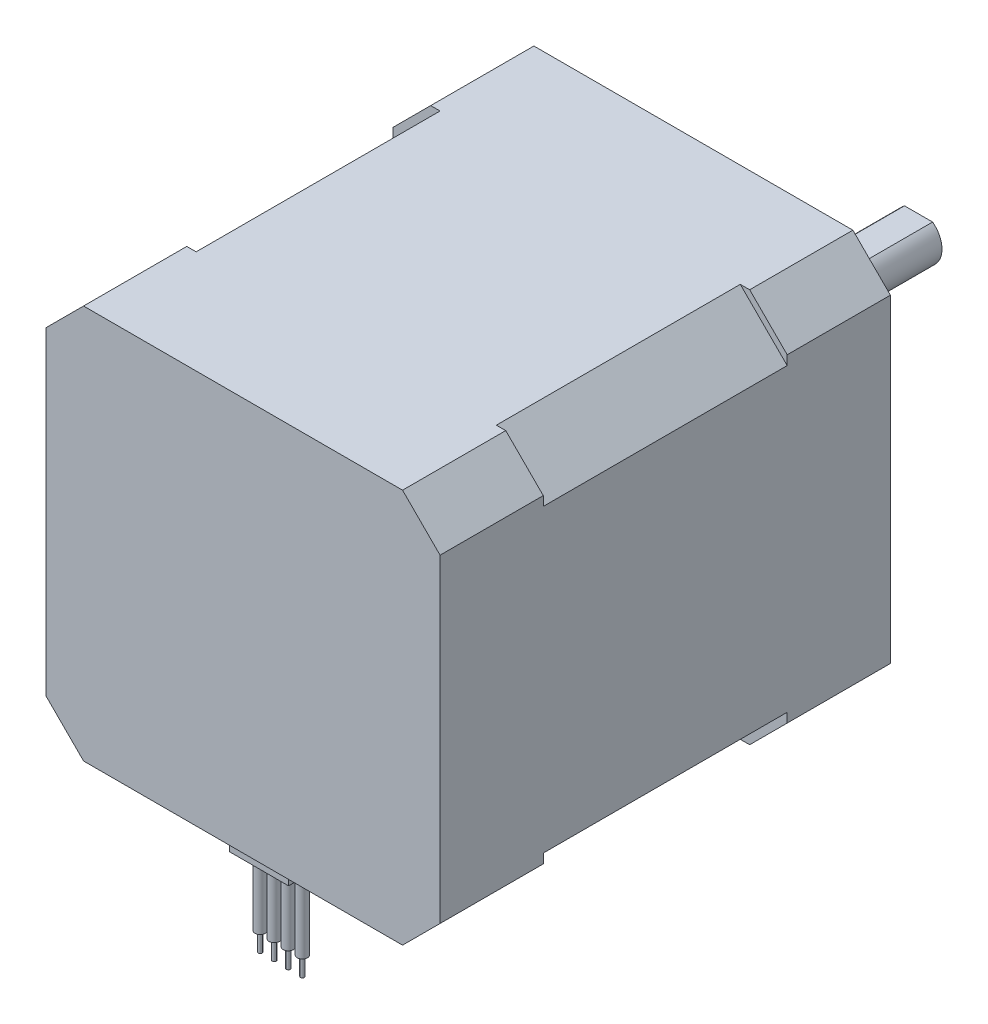
from build123d import *

# Parameters (mm, degrees)
BOSS_EXTRU_1_DEPTH      = 11
BOSS_EXTRU_2_DEPTH      = 26
BOSS_EXTRU_3_DEPTH      = 11
ESQUISSE4_R             = 11
BOSS_EXTRU_4_DEPTH      = 2
ESQUISSE5_R             = 2.5
BOSS_EXTRU_5_DEPTH      = 22
ESQUISSE6_W             = 5.798316384
ESQUISSE6_H             = 1
ENL_V_MAT_EXTRU_1_DEPTH = 18
TROU_TARAUD_M31_D       = 2.5
TROU_TARAUD_M31_DEPTH   = 7
TROU_TARAUD_M31_TIP     = 0.751075774
ESQUISSE9_W             = 6.3
ESQUISSE9_H             = 4.75
BOSS_EXTRU_6_DEPTH      = 2.3
ESQUISSE10_R            = 0.2025
BOSS_EXTRU_7_DEPTH      = 10
ESQUISSE11_R            = 0.55
BOSS_EXTRU_8_DEPTH      = 8


with BuildPart() as part:
    # Esquisse1 → Boss.-Extru.1 (new body)
    with BuildSketch(Plane.XY):
        Polygon((17, 21), (21, 17), (21, -17), (17, -21), (-17, -21), (-21, -17), (-21, 17), (-17, 21), align=None)
    extrude(amount=BOSS_EXTRU_1_DEPTH)

    # Esquisse2 → Boss.-Extru.2 (add)
    with BuildSketch(Plane(origin=(0, 0, 0), x_dir=(-1, 0, 0), z_dir=(0, 0, -1))):
        Polygon((-16, 21), (16, 21), (21, 16), (21, -16), (16, -21), (-16, -21), (-21, -16), (-21, 16), align=None)
    extrude(amount=BOSS_EXTRU_2_DEPTH)

    # Esquisse3 → Boss.-Extru.3 (add)
    with BuildSketch(Plane(origin=(0, 0, -26), x_dir=(-1, 0, 0), z_dir=(0, 0, -1))):
        Polygon((-17, 21), (-21, 17), (-21, -17), (-17, -21), (17, -21), (21, -17), (21, 17), (17, 21), align=None)
    extrude(amount=BOSS_EXTRU_3_DEPTH)

    # Esquisse4 → Boss.-Extru.4 (add)
    with BuildSketch(Plane(origin=(0, 0, -37), x_dir=(-1, 0, 0), z_dir=(0, 0, -1))):
        Circle(ESQUISSE4_R)
    extrude(amount=BOSS_EXTRU_4_DEPTH)

    # Esquisse5 → Boss.-Extru.5 (add)
    with BuildSketch(Plane(origin=(0, 0, -39), x_dir=(-1, 0, 0), z_dir=(0, 0, -1))):
        Circle(ESQUISSE5_R)
    extrude(amount=BOSS_EXTRU_5_DEPTH)

    # Esquisse6 → Enlèv. mat.-Extru.1 (cut)
    with BuildSketch(Plane(origin=(0, 0, -61), x_dir=(-1, 0, 0), z_dir=(0, 0, -1))):
        with Locations((0, 2.5)):
            Rectangle(ESQUISSE6_W, ESQUISSE6_H)
    extrude(amount=-ENL_V_MAT_EXTRU_1_DEPTH, mode=Mode.SUBTRACT)

    # Trou taraudé M31
    with Locations(Plane(origin=(0, 0, -37), x_dir=(-1, 0, 0), z_dir=(0, 0, -1))):
        with Locations((-15.5, 15.5), (15.5, 15.5), (15.5, -15.5), (-15.5, -15.5)):
            Hole(TROU_TARAUD_M31_D / 2, depth=TROU_TARAUD_M31_DEPTH)
            with Locations((0, 0, -(TROU_TARAUD_M31_DEPTH + TROU_TARAUD_M31_TIP / 2))):  # 118° drill point
                Cone(0, TROU_TARAUD_M31_D / 2, TROU_TARAUD_M31_TIP, mode=Mode.SUBTRACT)

    # Esquisse9 → Boss.-Extru.6 (add)
    with BuildSketch(Plane.XZ.offset(21)):
        with Locations((0, 6.925)):
            Rectangle(ESQUISSE9_W, ESQUISSE9_H)
    extrude(amount=BOSS_EXTRU_6_DEPTH)

    # Esquisse10 → Boss.-Extru.7 (add)
    with BuildSketch(Plane.XZ.offset(23.3)):
        with Locations((-2.25, 6.925)):
            Circle(ESQUISSE10_R)
        with Locations((-0.75, 6.925)):
            Circle(ESQUISSE10_R)
        with Locations((0.75, 6.925)):
            Circle(ESQUISSE10_R)
        with Locations((2.25, 6.925)):
            Circle(ESQUISSE10_R)
    extrude(amount=BOSS_EXTRU_7_DEPTH)

    # Esquisse11 → Boss.-Extru.8 (add)
    with BuildSketch(Plane.XZ.offset(23.3)):
        with Locations((-2.25, 6.925)):
            Circle(ESQUISSE11_R)
        with Locations((-0.75, 6.925)):
            Circle(ESQUISSE11_R)
        with Locations((0.75, 6.925)):
            Circle(ESQUISSE11_R)
        with Locations((2.25, 6.925)):
            Circle(ESQUISSE11_R)
    extrude(amount=BOSS_EXTRU_8_DEPTH)


solid = part.part
